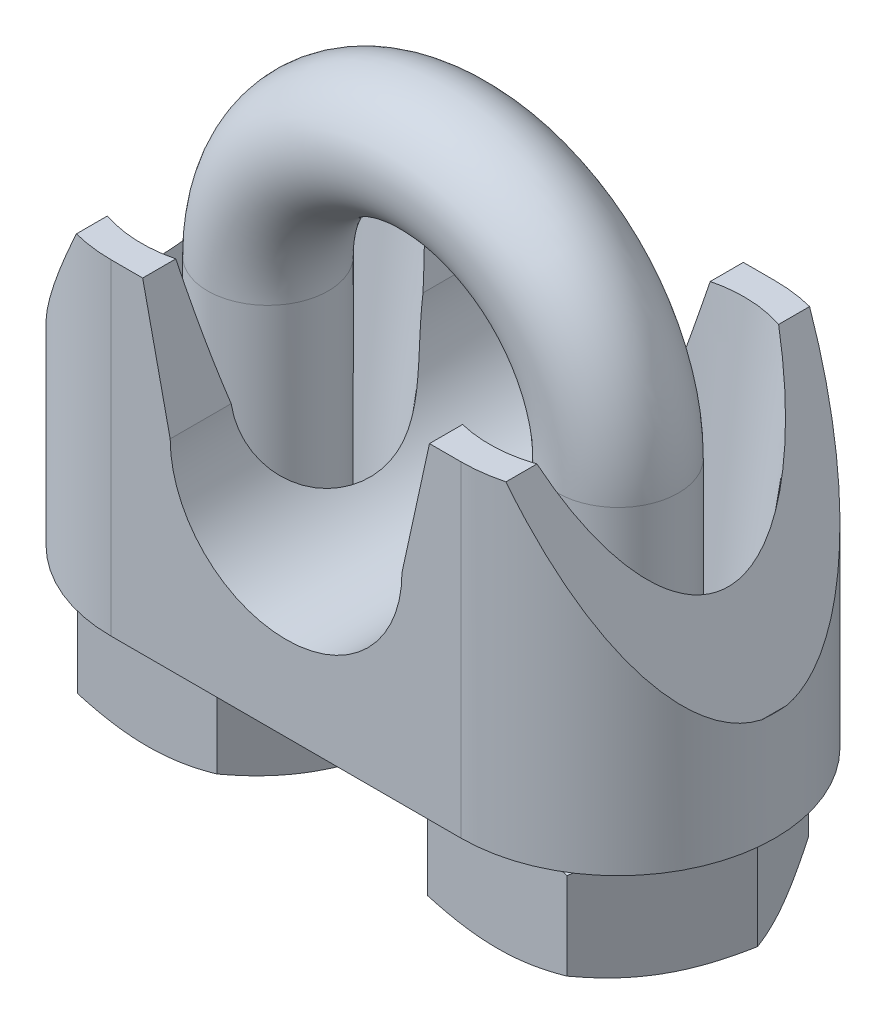
from build123d import *

# Parameters (mm, degrees)
BOSS_EXTRUDE1_DEPTH = 13.5
SKETCH2_R           = 3.625
CUT_EXTRUDE1_DEPTH  = 14.5
CUT_EXTRUDE1_TAPER  = -7
CUT_EXTRUDE2_DEPTH  = 14
CUT_EXTRUDE5_DEPTH  = 17
SWEEP1_PROFILE_R    = 2.5
BOSS_EXTRUDE2_DEPTH = 4.5


with BuildPart() as part:
    # Sketch1 → Boss-Extrude1 (new body)
    with BuildSketch(Plane(origin=(0, 0, 0), x_dir=(1, 0, 0), z_dir=(0, 1, 0))):
        with BuildLine():
            Line((0, 6.5), (14.5, 6.5))
            ThreePointArc((14.5, 6.5), (21, 0), (14.5, -6.5))
            Line((14.5, -6.5), (0, -6.5))
            ThreePointArc((0, -6.5), (-6.5, 0), (0, 6.5))
        make_face()
    extrude(amount=BOSS_EXTRUDE1_DEPTH)

    # Sketch2 → Cut-Extrude1 (cut, through all)
    with BuildSketch(Plane.XZ):
        with Locations((14.455, 0)):
            Circle(SKETCH2_R)
        with Locations((0.045, 0)):
            Circle(SKETCH2_R)
    extrude(amount=-CUT_EXTRUDE1_DEPTH, taper=CUT_EXTRUDE1_TAPER, mode=Mode.SUBTRACT)

    # Sketch3 → Cut-Extrude2 (cut, through all)
    with BuildSketch(Plane.XY.offset(6.5)):
        with BuildLine():
            Line((2.45, 8.3), (1.310642586, 13.5))
            Line((1.310642586, 13.5), (13.189357414, 13.5))
            Line((13.189357414, 13.5), (12.05, 8.3))
            ThreePointArc((12.05, 8.3), (7.25, 3.5), (2.45, 8.3))
        make_face()
    extrude(amount=-CUT_EXTRUDE2_DEPTH, mode=Mode.SUBTRACT)

    # Sketch5 → Cut-Extrude5 (cut, symmetric)
    with BuildSketch(Plane.XY):
        Polygon((14.455, 16.647940665), (20.97914525, 4.5), (22.832378007, 4.5), (22.832378007, 16.647940665), (21.179941679, 16.647940665), align=None)
        Polygon((-8.332378007, 4.5), (-6.47914525, 4.5), (0.045, 16.647940665), (-6.679941679, 16.647940665), (-8.332378007, 16.647940665), align=None)
    extrude(amount=CUT_EXTRUDE5_DEPTH, both=True, mode=Mode.SUBTRACT)


with BuildPart() as body_2:
    # Sweep1: sweep along a path in Sketch6
    with BuildLine(Plane.XY) as sweep1_path:
        Line((14.5, -4.7), (14.5, 0))
        Line((14.5, 0), (14.5, 10.38))
        ThreePointArc((14.5, 10.38), (7.25, 17.63), (0, 10.38))
        Line((0, 10.38), (0, 0))
        Line((0, 0), (0, -4.7))
    # Sweep1 profile (on start of the path) → Sweep1 (sweep)
    with BuildSketch(Plane(origin=(14.5, -4.7, 0), x_dir=(0, 0, 1), z_dir=(0, 1, 0))):
        Circle(SWEEP1_PROFILE_R)
    sweep(path=sweep1_path.line)

    # Sketch35 → Boss-Extrude2 (add)
    with BuildSketch(Plane.XZ.offset(4.7)):
        Polygon((11.613248654, -5), (17.386751346, -5), (20.273502692, 0), (17.386751346, 5), (11.613248654, 5), (8.726497308, 0), align=None)
        Polygon((5.773502692, 0), (2.886751346, -5), (-2.886751346, -5), (-5.773502692, 0), (-2.886751346, 5), (2.886751346, 5), align=None)
    extrude(amount=-BOSS_EXTRUDE2_DEPTH)

    # Sketch36 → Cut-Revolve2 (revolve, cut)
    with BuildSketch(Plane(origin=(0, 0, 0), x_dir=(0, 0, -1), z_dir=(1, 0, 0))):
        Polygon((5, -0.2), (7.150676764, -1.441693809), (7.150676764, -0.2), align=None)
        Polygon((5, -4.7), (7.313939087, -4.7), (7.313939087, -3.364046645), align=None)
    cut_revolve2 = revolve(axis=Axis((0, 0, 0), (0, -1, 0)), mode=Mode.SUBTRACT)

    # Mirror1: Cut-Revolve2 across plane
    add(cut_revolve2.mirror(Plane.ZY.offset(-7.25)), mode=Mode.SUBTRACT)


solid = Compound([part.part, body_2.part])
